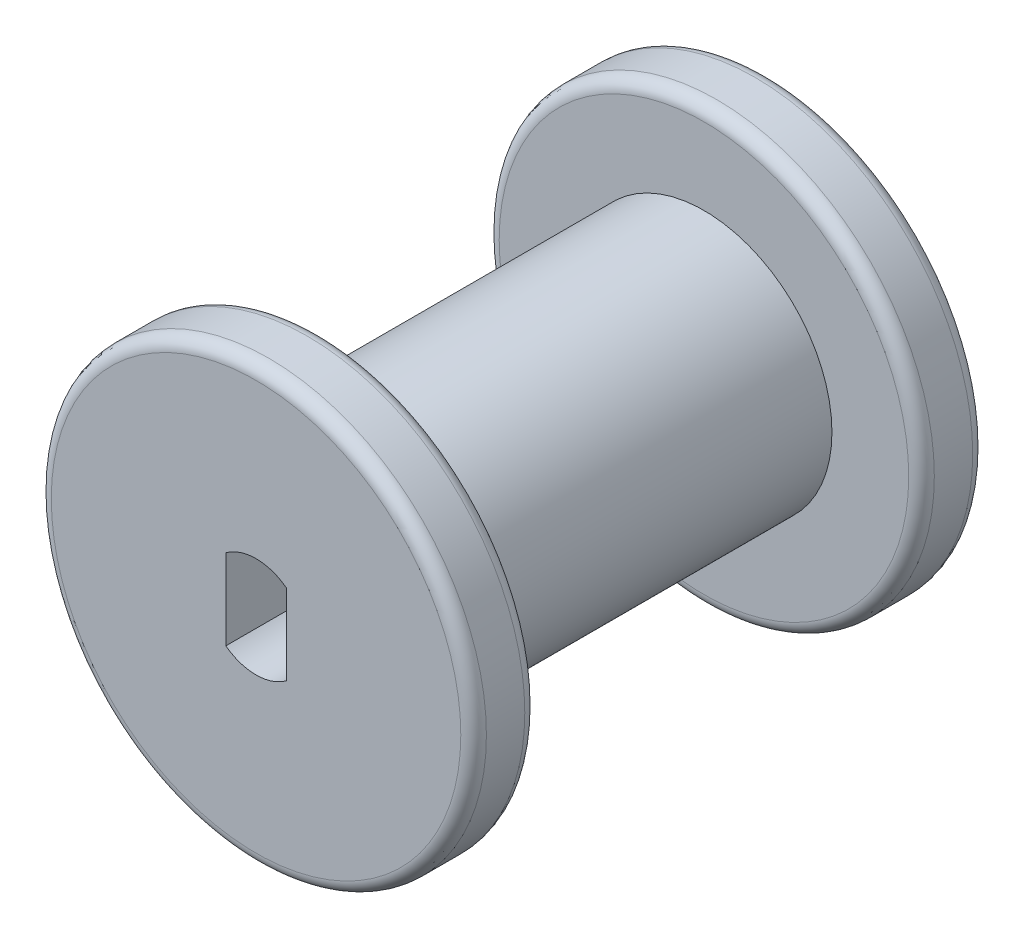
from build123d import *

# Parameters (mm, degrees)
SKETCH1_R           = 10.795
BOSS_EXTRUDE1_DEPTH = 25.4
SKETCH2_R           = 10.795
SKETCH2_R_2         = 6.35
CUT_EXTRUDE1_DEPTH  = 9.525
FILLET3_R           = 0.635


with BuildPart() as part:
    # Sketch1 → Boss-Extrude1 (new body)
    with BuildSketch(Plane.XY):
        Circle(SKETCH1_R)
        with BuildLine():
            Line((1.5, -2), (1.5, 2))
            ThreePointArc((1.5, 2), (0, 2.5), (-1.5, 2))
            Line((-1.5, 2), (-1.5, -2))
            ThreePointArc((-1.5, -2), (0, -2.5), (1.5, -2))
        make_face(mode=Mode.SUBTRACT)
    extrude(amount=BOSS_EXTRUDE1_DEPTH)

    # Sketch2 → Cut-Extrude1 (cut, symmetric)
    with BuildSketch(Plane.XY.offset(12.7)):
        Circle(SKETCH2_R)
        Circle(SKETCH2_R_2, mode=Mode.SUBTRACT)
    extrude(amount=CUT_EXTRUDE1_DEPTH, both=True, mode=Mode.SUBTRACT)

    # Fillet3
    fillet3_edges = [part.edges().sort_by_distance(p)[0] for p in [
        (-10.795, 0, 0),
        (-10.795, 0, 3.175),
        (-10.795, 0, 22.225),
        (-10.795, 0, 25.4),
    ]]
    fillet(fillet3_edges, radius=FILLET3_R)


solid = part.part
